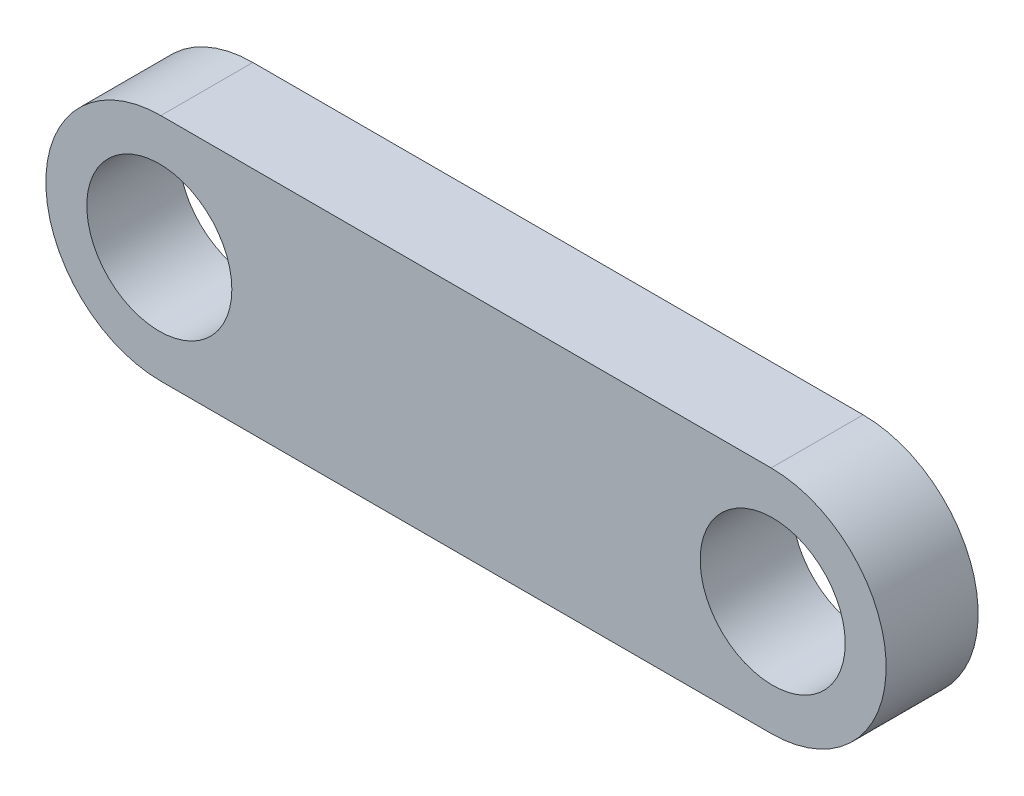
from build123d import *

# Parameters (mm, degrees)
SKETCH1_R           = 2.395
BOSS_EXTRUDE1_DEPTH = 3
SKETCH2_R           = 2.365
BOSS_EXTRUDE2_DEPTH = 3


with BuildPart() as part:
    # Sketch1 → Boss-Extrude1 (new body)
    with BuildSketch(Plane.XY):
        with BuildLine():
            Line((0, 3), (20, 3))
            ThreePointArc((20, 3), (23, 0), (20, -3))
            Line((20, -3), (0, -3))
            ThreePointArc((0, -3), (-3, 0), (0, 3))
        make_face()
        Circle(SKETCH1_R, mode=Mode.SUBTRACT)
        with Locations((20, 0)):
            Circle(SKETCH1_R, mode=Mode.SUBTRACT)
    extrude(amount=BOSS_EXTRUDE1_DEPTH)

    # Sketch2 → Boss-Extrude2 (add)
    with BuildSketch(Plane.XY.offset(3)):
        with BuildLine():
            Line((0.05, 3.75), (19.95, 3.75))
            ThreePointArc((19.95, 3.75), (23.7, 0), (19.95, -3.75))
            Line((19.95, -3.75), (0.05, -3.75))
            ThreePointArc((0.05, -3.75), (-3.7, 0), (0.05, 3.75))
        make_face()
        Circle(SKETCH2_R, mode=Mode.SUBTRACT)
        with Locations((20, 0)):
            Circle(SKETCH2_R, mode=Mode.SUBTRACT)
    extrude(amount=-BOSS_EXTRUDE2_DEPTH)


solid = part.part
